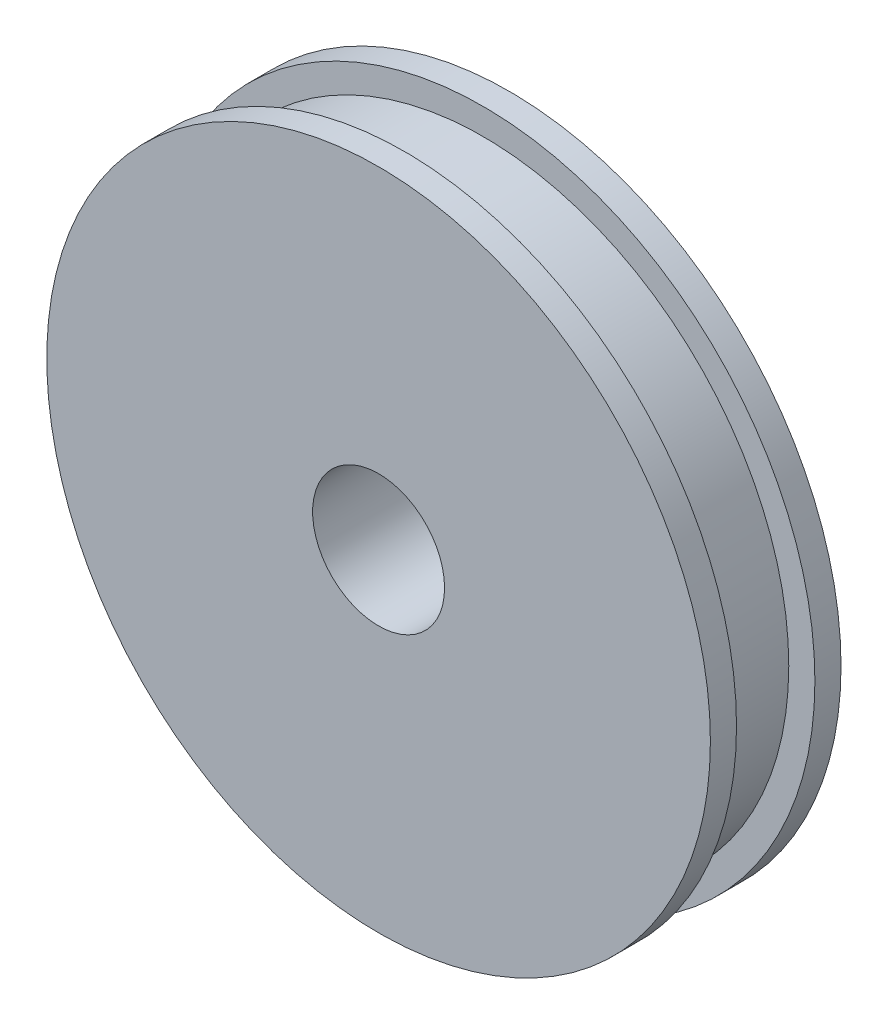
from build123d import *

# Parameters (mm, degrees)
CROQUIS1_R              = 25.4
CROQUIS1_R_2            = 5.05
SALIENTE_EXTRUIR1_DEPTH = 10
CROQUIS2_W              = 6
CROQUIS2_H              = 2


with BuildPart() as part:
    # Croquis1 → Saliente-Extruir1 (new body)
    with BuildSketch(Plane.XY):
        Circle(CROQUIS1_R)
        Circle(CROQUIS1_R_2, mode=Mode.SUBTRACT)
    extrude(amount=SALIENTE_EXTRUIR1_DEPTH)

    # Croquis2 → Cortar-Revolución1 (revolve, cut)
    with BuildSketch(Plane(origin=(0, 0, 0), x_dir=(0, 0, -1), z_dir=(1, 0, 0))):
        with Locations((-5, 24.4)):
            Rectangle(CROQUIS2_W, CROQUIS2_H)
    revolve(axis=Axis((0, 0, 10), (0, 0, -1)), mode=Mode.SUBTRACT)


solid = part.part
